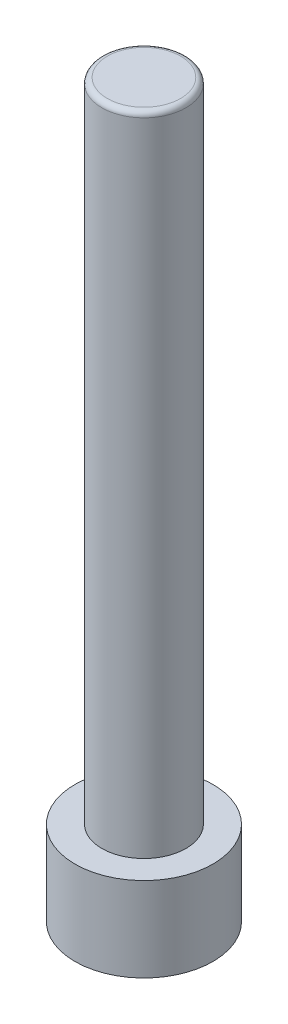
from build123d import *

# Parameters (mm, degrees)
SKETCH1_R           = 6.4
BOSS_EXTRUDE1_DEPTH = 67.83
SKETCH2_OUTSIDE_W   = 28.84
SKETCH2_OUTSIDE_H   = 28.84
SKETCH2_OUTSIDE_R   = 3.9
CUT_EXTRUDE1_DEPTH  = 60
CUT_EXTRUDE2_DEPTH  = 5.64
FILLET1_R           = 0.5


with BuildPart() as part:
    # Sketch1 → Boss-Extrude1 (new body)
    with BuildSketch(Plane(origin=(0, 0, 0), x_dir=(1, 0, 0), z_dir=(0, 1, 0))):
        Circle(SKETCH1_R)
    extrude(amount=BOSS_EXTRUDE1_DEPTH)

    # Sketch2 outside → Cut-Extrude1 (cut)
    with BuildSketch(Plane(origin=(0, 67.83, 0), x_dir=(1, 0, 0), z_dir=(0, 1, 0))):
        Rectangle(SKETCH2_OUTSIDE_W, SKETCH2_OUTSIDE_H)
        Circle(SKETCH2_OUTSIDE_R, mode=Mode.SUBTRACT)
    extrude(amount=-CUT_EXTRUDE1_DEPTH, mode=Mode.SUBTRACT)

    # Sketch8 → Cut-Extrude2 (cut)
    with BuildSketch(Plane.XZ):
        Polygon((3.464101615, 0), (1.732050808, 3), (-1.732050808, 3), (-3.464101615, 0), (-1.732050808, -3), (1.732050808, -3), align=None)
    extrude(amount=-CUT_EXTRUDE2_DEPTH, mode=Mode.SUBTRACT)

    # Fillet1
    fillet1_edges = [part.edges().sort_by_distance(p)[0] for p in [
        (-3.9, 67.83, 0),
    ]]
    fillet(fillet1_edges, radius=FILLET1_R)


solid = part.part
